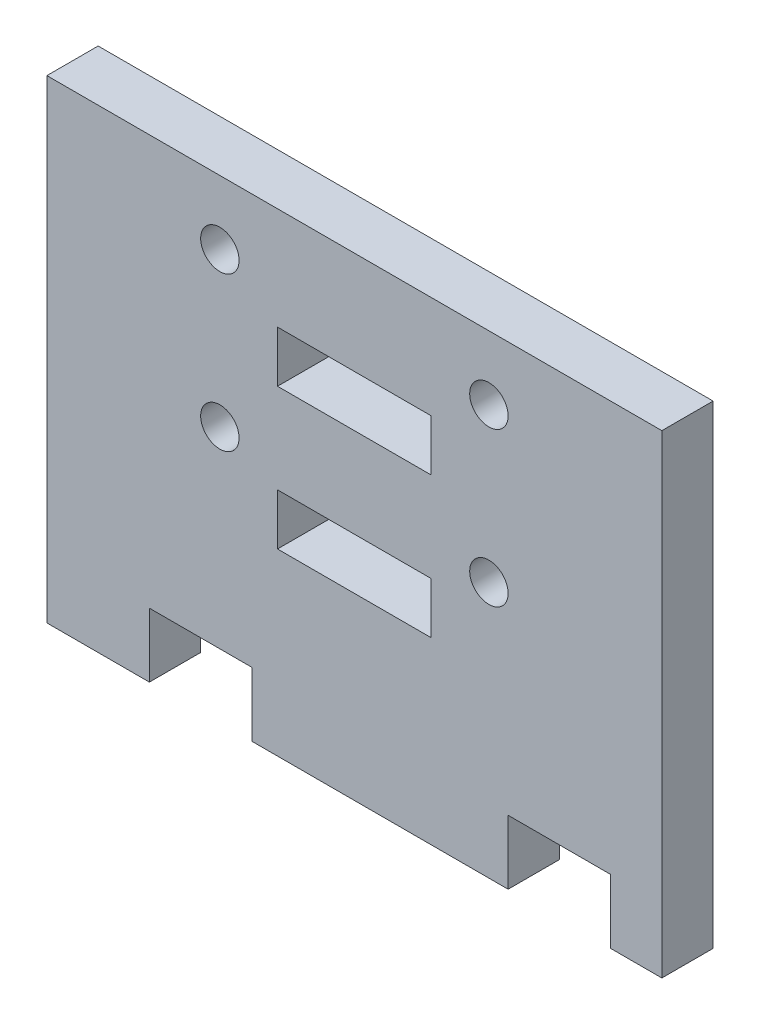
from build123d import *

# Parameters (mm, degrees)
SKETCH1_R           = 0.75
SKETCH1_W           = 6
SKETCH1_H           = 2
BOSS_EXTRUDE1_DEPTH = 2


with BuildPart() as part:
    # Sketch1 → Boss-Extrude1 (new body)
    with BuildSketch(Plane.XY):
        Polygon((4, 2.5), (8, 2.5), (8, 0), (18, 0), (18, 2.5), (22, 2.5), (22, 0), (24, 0), (24, 18.5), (0, 18.5), (0, 0), (4, 0), align=None)
        with Locations((6.75, 16)):
            Circle(SKETCH1_R, mode=Mode.SUBTRACT)
        with Locations((17.25, 16)):
            Circle(SKETCH1_R, mode=Mode.SUBTRACT)
        with Locations((17.25, 10)):
            Circle(SKETCH1_R, mode=Mode.SUBTRACT)
        with Locations((6.75, 10)):
            Circle(SKETCH1_R, mode=Mode.SUBTRACT)
        with Locations((12, 13.5)):
            Rectangle(SKETCH1_W, SKETCH1_H, mode=Mode.SUBTRACT)
        with Locations((12, 8)):
            Rectangle(SKETCH1_W, SKETCH1_H, mode=Mode.SUBTRACT)
    extrude(amount=BOSS_EXTRUDE1_DEPTH)


solid = part.part
